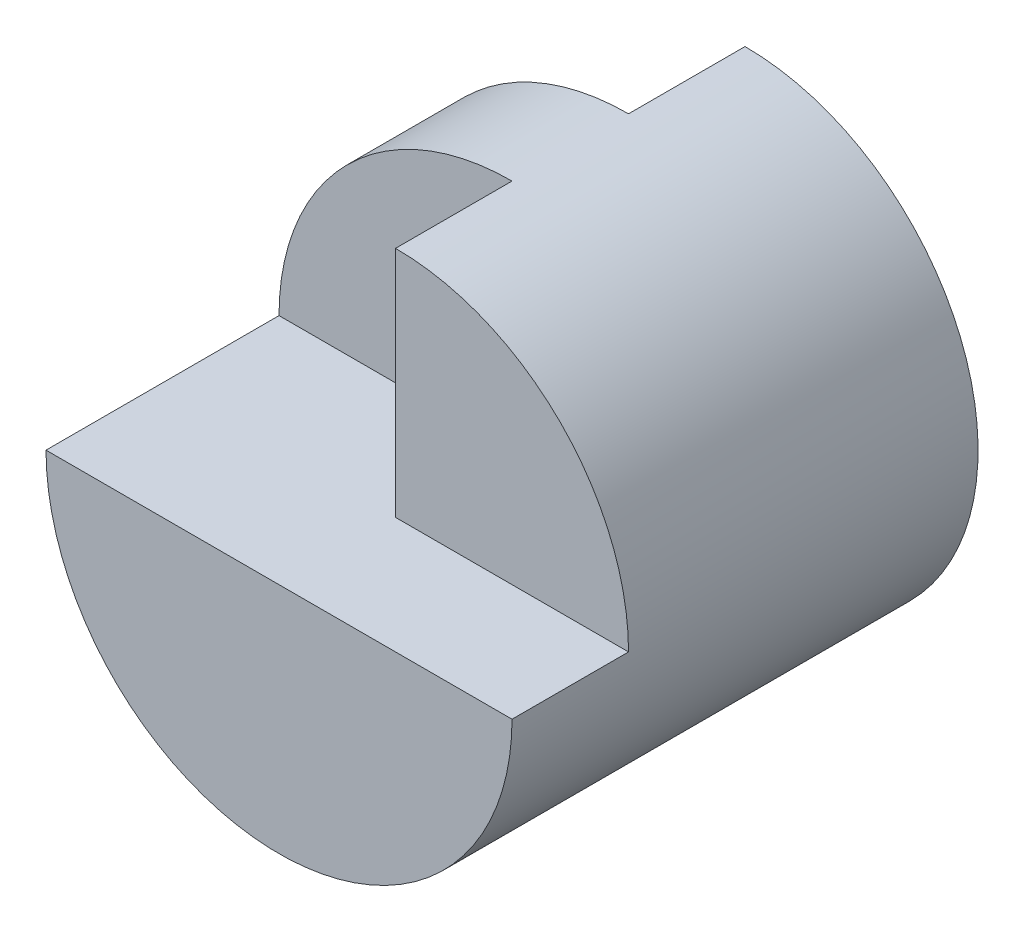
from build123d import *

# Parameters (mm, degrees)
SKETCH2_R               = 20
BOSS_EXTRUDE1_DEPTH     = 40
CUT_EXTRUDE1_DEPTH      = 40
CUT_EXTRUDE1_DEPTH_BACK = 40
SKETCH3_W               = 10
SKETCH3_H               = 20
CUT_EXTRUDE2_START      = -10
CUT_EXTRUDE2_DEPTH      = 10
CUT_EXTRUDE3_DEPTH      = 10


with BuildPart() as part:
    # Sketch2 → Boss-Extrude1 (new body)
    with BuildSketch(Plane.XY):
        Circle(SKETCH2_R)
    extrude(amount=BOSS_EXTRUDE1_DEPTH)

    # Sketch3 → Cut-Extrude1 (cut, two sides: drawn at the far end of the back side and taken through both)
    with BuildSketch(Plane(origin=(0, 0, 0), x_dir=(0, 0, -1), z_dir=(1, 0, 0)).offset(-CUT_EXTRUDE1_DEPTH_BACK)):
        with Locations((-35, 10)):
            Rectangle(SKETCH3_W, SKETCH3_H)
    extrude(amount=CUT_EXTRUDE1_DEPTH + CUT_EXTRUDE1_DEPTH_BACK, mode=Mode.SUBTRACT)

    # Sketch4 → Cut-Extrude2 (cut)
    with BuildSketch(Plane.XY.offset(30).offset(CUT_EXTRUDE2_START)):
        with BuildLine():
            Line((-20, 0), (0, 0))
            Line((0, 0), (0, 20))
            ThreePointArc((0, 20), (-14.142135624, 14.142135624), (-20, 0))
        make_face()
    extrude(amount=CUT_EXTRUDE2_DEPTH, mode=Mode.SUBTRACT)

    # Sketch5 → Cut-Extrude3 (cut)
    with BuildSketch(Plane(origin=(0, 0, 0), x_dir=(-1, 0, 0), z_dir=(0, 0, -1))):
        with BuildLine():
            Line((0, 20), (0, 0))
            Line((0, 0), (20, 0))
            ThreePointArc((20, 0), (14.142135624, 14.142135624), (0, 20))
        make_face()
    extrude(amount=-CUT_EXTRUDE3_DEPTH, mode=Mode.SUBTRACT)


solid = part.part
